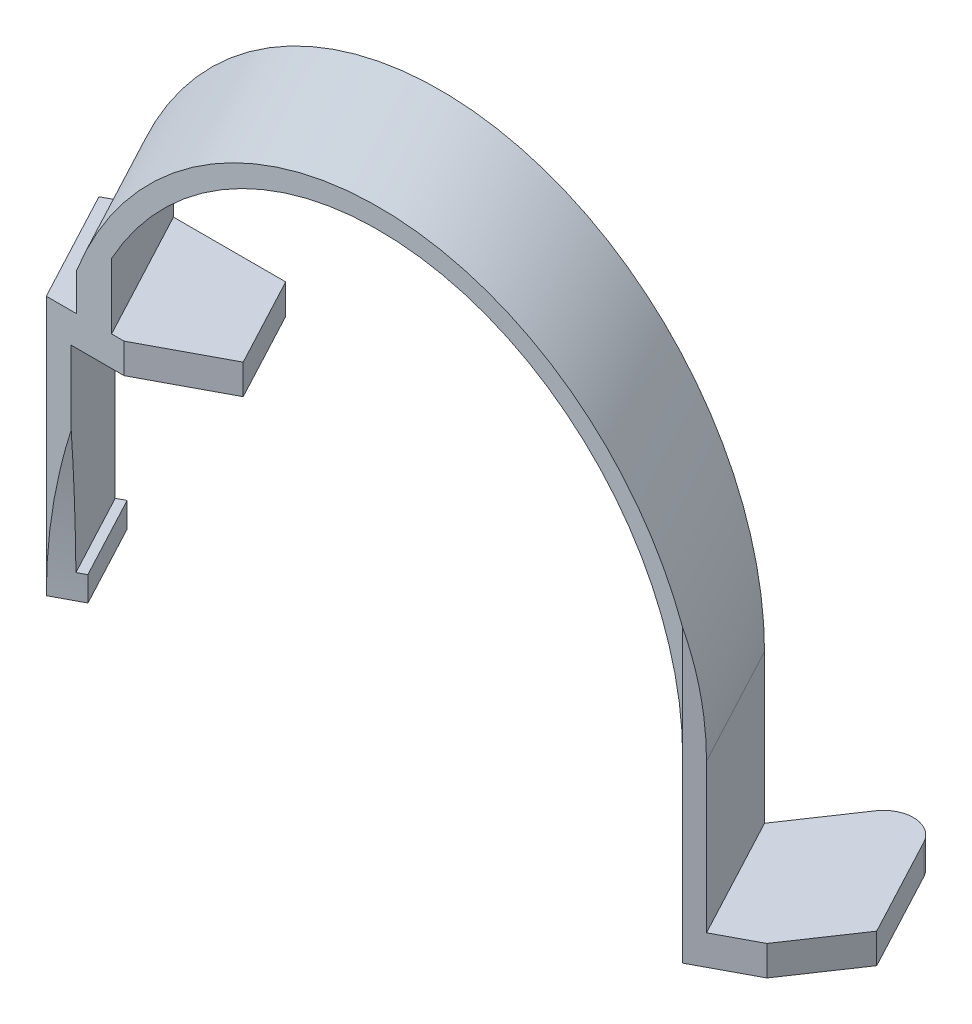
from build123d import *

# Parameters (mm, degrees)
CORTE_EXTRUS_O1_DEPTH      = 51.4
CORTE_EXTRUS_O2_DEPTH      = 73.874980511
CHANFRO1_SIZE              = 10
CHANFRO1_SIZE2             = 4.694715628
ESBO_O6_W                  = 5.368395338
ESBO_O6_H                  = 18.334195556
CORTE_EXTRUS_O3_DEPTH      = 5
CORTE_EXTRUS_O3_DEPTH_BACK = 5
RESSALTO_EXTRUS_O2_DEPTH   = 3
CHANFRO2_SIZE              = 7
CHANFRO2_SIZE2             = 3.721966022
FILETE2_R                  = 3


with BuildPart() as part:
    # Varredura2: sweep along a path in Esboço2
    with BuildLine(Plane(origin=(0, 0, 0), x_dir=(1, 0, 0), z_dir=(0, 1, 0))) as varredura2_path:
        Line((0, 0), (-7.042073442, 13.244213893))
    # Esboço1<3> → Varredura2 (sweep)
    with BuildSketch(Plane.XY):
        with BuildLine():
            Line((30.5, 0), (30.5, -17.9))
            Line((30.5, -17.9), (45.5, -17.9))
            Line((45.5, -17.9), (45.5, -14.9))
            Line((45.5, -14.9), (32.5, -14.9))
            Line((32.5, -14.9), (32.5, 0))
            ThreePointArc((32.5, 0), (6.046693311, 31.932546093), (-30.25, 11.882234638))
            Line((-30.25, 11.882234638), (-30.25, 8.1))
            Line((-30.25, 8.1), (-33.3, 8.1))
            Line((-33.3, 8.1), (-33.3, -17.9))
            Line((-33.3, -17.9), (-30.8, -17.9))
            Line((-30.8, -17.9), (-29.8, -17.9))
            Line((-29.8, -17.9), (-29.8, -15.416139266))
            Line((-29.8, -15.416139266), (-30.8, -15.416139266))
            Line((-30.8, -15.416139266), (-30.8, 5.1))
            Line((-30.8, 5.1), (-26.75, 5.1))
            Line((-26.75, 5.1), (-15.5, 5.1))
            Line((-15.5, 5.1), (-15.5, 8.1))
            Line((-15.5, 8.1), (-26.75, 8.1))
            Line((-26.75, 8.1), (-26.75, 14.652218262))
            ThreePointArc((-26.75, 14.652218262), (7.562241731, 29.547631039), (30.5, 0))
        make_face()
    sweep(path=varredura2_path.line)

    # Esboço4 → Corte-extrusão1 (cut, through all)
    with BuildSketch(Plane.XZ.offset(17.9)):
        Polygon((42.193946776, -6.217781794), (30.5, 0), (45.5, 0), align=None)
    extrude(amount=-CORTE_EXTRUS_O1_DEPTH, mode=Mode.SUBTRACT)

    # Esboço5 → Corte-extrusão2 (cut, through all)
    with BuildSketch(Plane(origin=(-25.960561843, 0, 13.803475583), x_dir=(0.469471563, 0, 0.882947593), z_dir=(-0.882947593, 0, 0.469471563))):
        with BuildLine():
            Line((-30.633403041, -17.9), (-25.133403041, -17.9))
            Line((-25.133403041, -17.9), (-25.133403041, -2.9))
            ThreePointArc((-25.133403041, -2.9), (-26.599119213, 2.806356105), (-30.633403041, 7.1))
            Line((-30.633403041, 7.1), (-30.633403041, -17.9))
        make_face()
        with BuildLine():
            Line((-13.16947903, 4.679780509), (-13.16947903, -17.9))
            Line((-13.16947903, -17.9), (-15.633403041, -17.9))
            ThreePointArc((-15.633403041, -17.9), (-15.015599199, -6.543092307), (-13.16947903, 4.679780509))
        make_face()
    extrude(amount=-CORTE_EXTRUS_O2_DEPTH, mode=Mode.SUBTRACT)

    # Chanfro1
    chanfro1_edges = [part.edges().sort_by_distance(p)[0] for p in [
        (-15.5, 6.6, 0),
    ]]
    chanfro1_side = [part.faces().sort_by_distance(p)[0] for p in [
        (-23.15, 5.913055964, 0),
    ]]
    chamfer(chanfro1_edges, length=CHANFRO1_SIZE, length2=CHANFRO1_SIZE2, reference=chanfro1_side[0])

    # Esboço6 → Corte-extrusão3 (cut, two sides)
    with BuildSketch(Plane(origin=(-24.011570713, 0, 12.767178617), x_dir=(-0.469471563, 0, -0.882947593), z_dir=(0.882947593, 0, -0.469471563))) as corte_extrus_o3_sk:
        with Locations((31.085712443, 8.557015368)):
            Rectangle(ESBO_O6_W, ESBO_O6_H)
    extrude(amount=CORTE_EXTRUS_O3_DEPTH, mode=Mode.SUBTRACT)
    extrude(corte_extrus_o3_sk.sketch, amount=-CORTE_EXTRUS_O3_DEPTH_BACK, mode=Mode.SUBTRACT)

    # Esboço7 → Ressalto-extrusão2 (add)
    with BuildSketch(Plane(origin=(0, -14.9, 0), x_dir=(1, 0, 0), z_dir=(0, 1, 0))):
        Polygon((25.457926558, 13.244213893), (32.727434303, 24.021702336), (38.457926558, 13.244213893), align=None)
    extrude(amount=-RESSALTO_EXTRUS_O2_DEPTH)

    # Chanfro2
    chanfro2_edges = [part.edges().sort_by_distance(p)[0] for p in [
        (42.193946776, -16.4, -6.217781794),
    ]]
    chanfro2_side = [part.faces().sort_by_distance(p)[0] for p in [
        (36.346973388, -17.580051063, -3.108890897),
    ]]
    chamfer(chanfro2_edges, length=CHANFRO2_SIZE, length2=CHANFRO2_SIZE2, reference=chanfro2_side[0])

    # Filete2
    filete2_edges = [part.edges().sort_by_distance(p)[0] for p in [
        (32.727434303, -16.4, -24.021702336),
    ]]
    fillet(filete2_edges, radius=FILETE2_R)


solid = part.part
